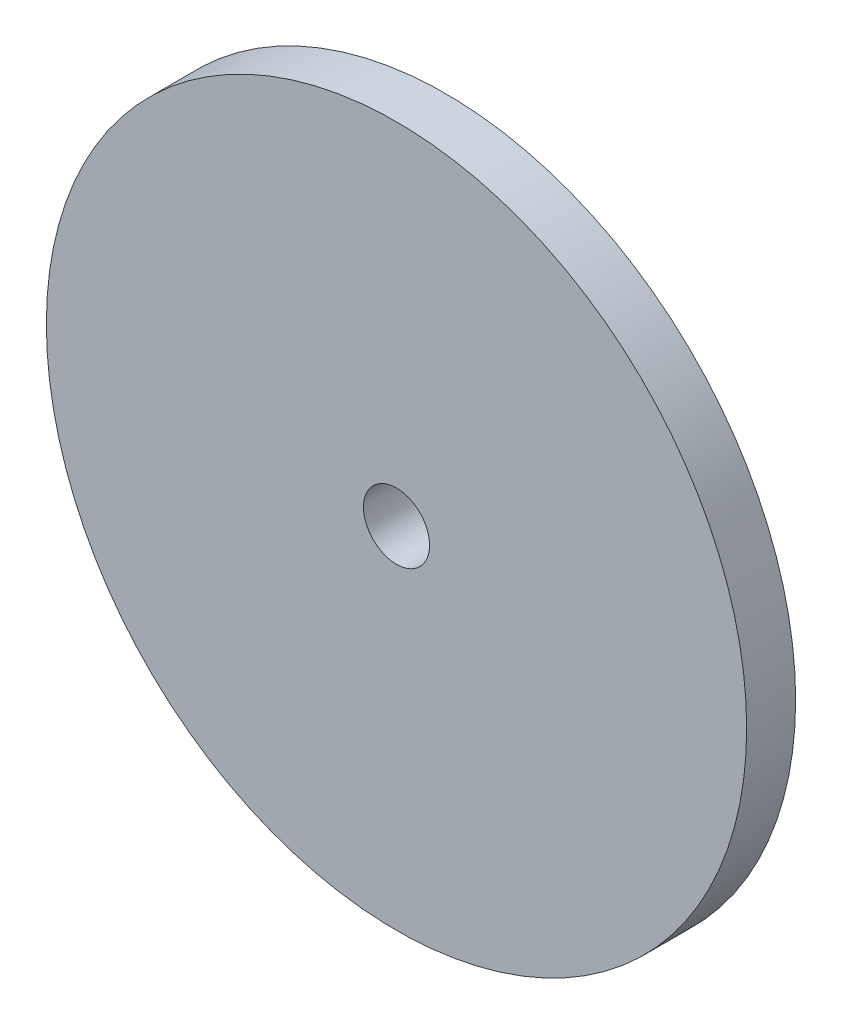
from build123d import *

# Parameters (mm, degrees)
ESQUISSE1_R        = 14.3
ESQUISSE1_R_2      = 1.35
BOSS_EXTRU_3_DEPTH = 2


with BuildPart() as part:
    # Esquisse1 → Boss.-Extru.3 (new body)
    with BuildSketch(Plane.XY):
        Circle(ESQUISSE1_R)
        Circle(ESQUISSE1_R_2, mode=Mode.SUBTRACT)
    extrude(amount=BOSS_EXTRU_3_DEPTH)


solid = part.part
